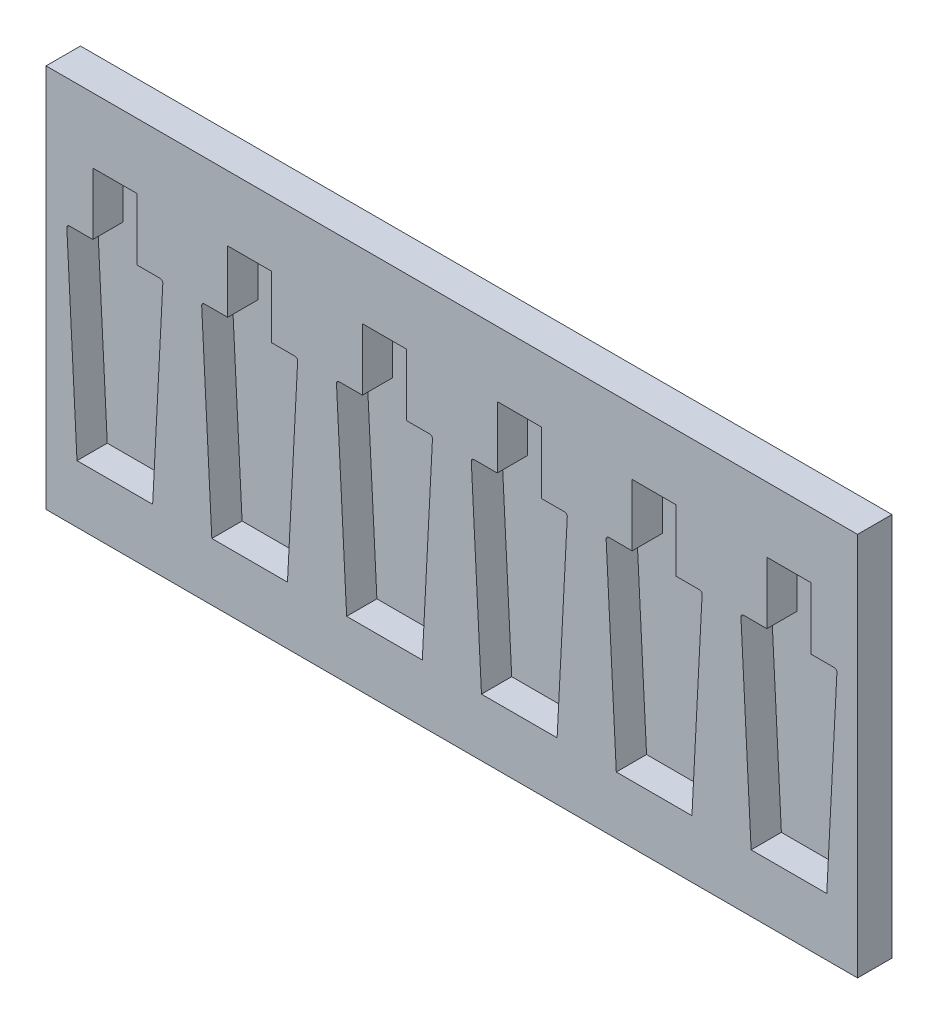
from build123d import *

# Parameters (mm, degrees)
SKETCH2_W           = 590
SKETCH2_H           = 279.33
BOSS_EXTRUDE1_DEPTH = 25
CUT_EXTRUDE1_DEPTH  = 22


with BuildPart() as part:
    # Sketch2 → Boss-Extrude1 (new body)
    with BuildSketch(Plane.XY):
        Rectangle(SKETCH2_W, SKETCH2_H)
    extrude(amount=BOSS_EXTRUDE1_DEPTH)

    # Sketch4 → Cut-Extrude1 (cut)
    with BuildSketch(Plane.XY.offset(25)):
        with BuildLine():
            Line((-261, 47.335), (-277.893878125, 47.335))
            ThreePointArc((-277.893878125, 47.335), (-279.344157467, 46.712203627), (-279.891208095, 45.231689829))
            Line((-279.891208095, 45.231689829), (-272.5, -97.665))
            Line((-272.5, -97.665), (-217.5, -97.665))
            Line((-217.5, -97.665), (-210.108791905, 45.231689829))
            ThreePointArc((-210.108791905, 45.231689829), (-210.655842533, 46.712203627), (-212.106121875, 47.335))
            Line((-212.106121875, 47.335), (-229, 47.335))
            Line((-229, 47.335), (-229, 92.335))
            Line((-229, 92.335), (-261, 92.335))
            Line((-261, 92.335), (-261, 47.335))
        make_face()
        with BuildLine():
            Line((-21.456483238, -97.665), (-14.065275143, 45.231689829))
            ThreePointArc((-14.065275143, 45.231689829), (-14.612325771, 46.712203627), (-16.062605113, 47.335))
            Line((-16.062605113, 47.335), (-32.956483238, 47.335))
            Line((-32.956483238, 47.335), (-32.956483238, 92.335))
            Line((-32.956483238, 92.335), (-64.956483238, 92.335))
            Line((-64.956483238, 92.335), (-64.956483238, 47.335))
            Line((-64.956483238, 47.335), (-81.850361363, 47.335))
            ThreePointArc((-81.850361363, 47.335), (-83.300640705, 46.712203627), (-83.847691332, 45.231689829))
            Line((-83.847691332, 45.231689829), (-76.456483238, -97.665))
            Line((-76.456483238, -97.665), (-21.456483238, -97.665))
        make_face()
        with BuildLine():
            Line((-181.869449714, 45.231689829), (-174.478241619, -97.665))
            Line((-174.478241619, -97.665), (-119.478241619, -97.665))
            Line((-119.478241619, -97.665), (-112.087033524, 45.231689829))
            ThreePointArc((-112.087033524, 45.231689829), (-112.634084152, 46.712203627), (-114.084363494, 47.335))
            Line((-114.084363494, 47.335), (-130.978241619, 47.335))
            Line((-130.978241619, 47.335), (-130.978241619, 92.335))
            Line((-130.978241619, 92.335), (-162.978241619, 92.335))
            Line((-162.978241619, 92.335), (-162.978241619, 47.335))
            Line((-162.978241619, 47.335), (-179.872119744, 47.335))
            ThreePointArc((-179.872119744, 47.335), (-181.322399086, 46.712203627), (-181.869449714, 45.231689829))
        make_face()
        with BuildLine():
            Line((76.565275143, -97.665), (83.956483238, 45.231689829))
            ThreePointArc((83.956483238, 45.231689829), (83.40943261, 46.712203627), (81.959153268, 47.335))
            Line((81.959153268, 47.335), (65.065275143, 47.335))
            Line((65.065275143, 47.335), (65.065275143, 92.335))
            Line((65.065275143, 92.335), (33.065275143, 92.335))
            Line((33.065275143, 92.335), (33.065275143, 47.335))
            Line((33.065275143, 47.335), (16.171397019, 47.335))
            ThreePointArc((16.171397019, 47.335), (14.721117676, 46.712203627), (14.174067049, 45.231689829))
            Line((14.174067049, 45.231689829), (21.565275143, -97.665))
            Line((21.565275143, -97.665), (76.565275143, -97.665))
        make_face()
        with BuildLine():
            Line((174.587033524, -97.665), (181.978241619, 45.231689829))
            ThreePointArc((181.978241619, 45.231689829), (181.431190991, 46.712203627), (179.980911649, 47.335))
            Line((179.980911649, 47.335), (163.087033524, 47.335))
            Line((163.087033524, 47.335), (163.087033524, 92.335))
            Line((163.087033524, 92.335), (131.087033524, 92.335))
            Line((131.087033524, 92.335), (131.087033524, 47.335))
            Line((131.087033524, 47.335), (114.1931554, 47.335))
            ThreePointArc((114.1931554, 47.335), (112.742876057, 46.712203627), (112.19582543, 45.231689829))
            Line((112.19582543, 45.231689829), (119.587033524, -97.665))
            Line((119.587033524, -97.665), (174.587033524, -97.665))
        make_face()
        with BuildLine():
            Line((210.217583811, 45.231689829), (217.608791905, -97.665))
            Line((217.608791905, -97.665), (272.608791905, -97.665))
            Line((272.608791905, -97.665), (280, 45.231689829))
            ThreePointArc((280, 45.231689829), (279.452949372, 46.712203627), (278.00267003, 47.335))
            Line((278.00267003, 47.335), (261.108791905, 47.335))
            Line((261.108791905, 47.335), (261.108791905, 92.335))
            Line((261.108791905, 92.335), (229.108791905, 92.335))
            Line((229.108791905, 92.335), (229.108791905, 47.335))
            Line((229.108791905, 47.335), (212.214913781, 47.335))
            ThreePointArc((212.214913781, 47.335), (210.764634438, 46.712203627), (210.217583811, 45.231689829))
        make_face()
    extrude(amount=-CUT_EXTRUDE1_DEPTH, mode=Mode.SUBTRACT)


solid = part.part
